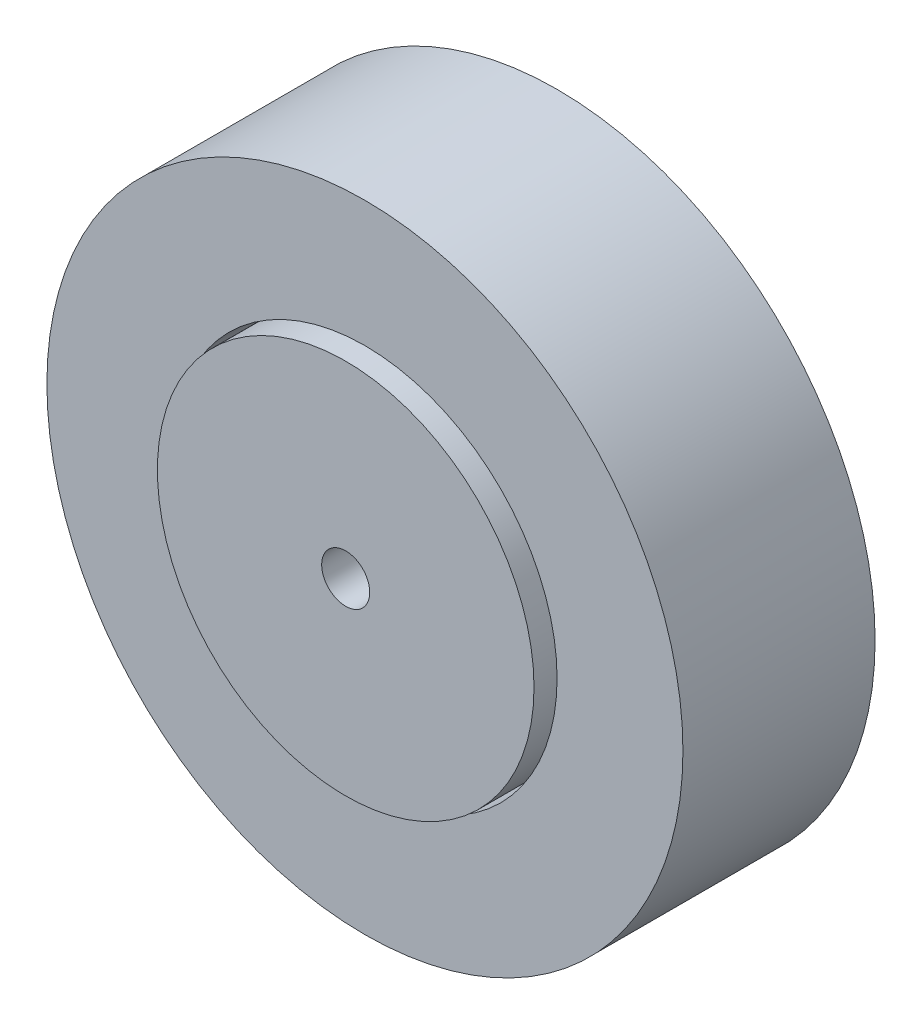
from build123d import *

# Parameters (mm, degrees)
SKETCH1_R           = 12.446
SKETCH1_R_2         = 1.5875
BOSS_EXTRUDE1_DEPTH = 7.62
SKETCH2_R           = 21.0185
SKETCH2_R_2         = 12.7
BOSS_EXTRUDE2_DEPTH = 6.35


with BuildPart() as part:
    # Sketch1 → Boss-Extrude1 (new body, symmetric)
    with BuildSketch(Plane.XY):
        Circle(SKETCH1_R)
        Circle(SKETCH1_R_2, mode=Mode.SUBTRACT)
    extrude(amount=BOSS_EXTRUDE1_DEPTH, both=True)


with BuildPart() as body_2:
    # Sketch2 → Boss-Extrude2 (new body, symmetric)
    with BuildSketch(Plane.XY):
        Circle(SKETCH2_R)
        Circle(SKETCH2_R_2, mode=Mode.SUBTRACT)
    extrude(amount=BOSS_EXTRUDE2_DEPTH, both=True)


solid = Compound([part.part, body_2.part])
